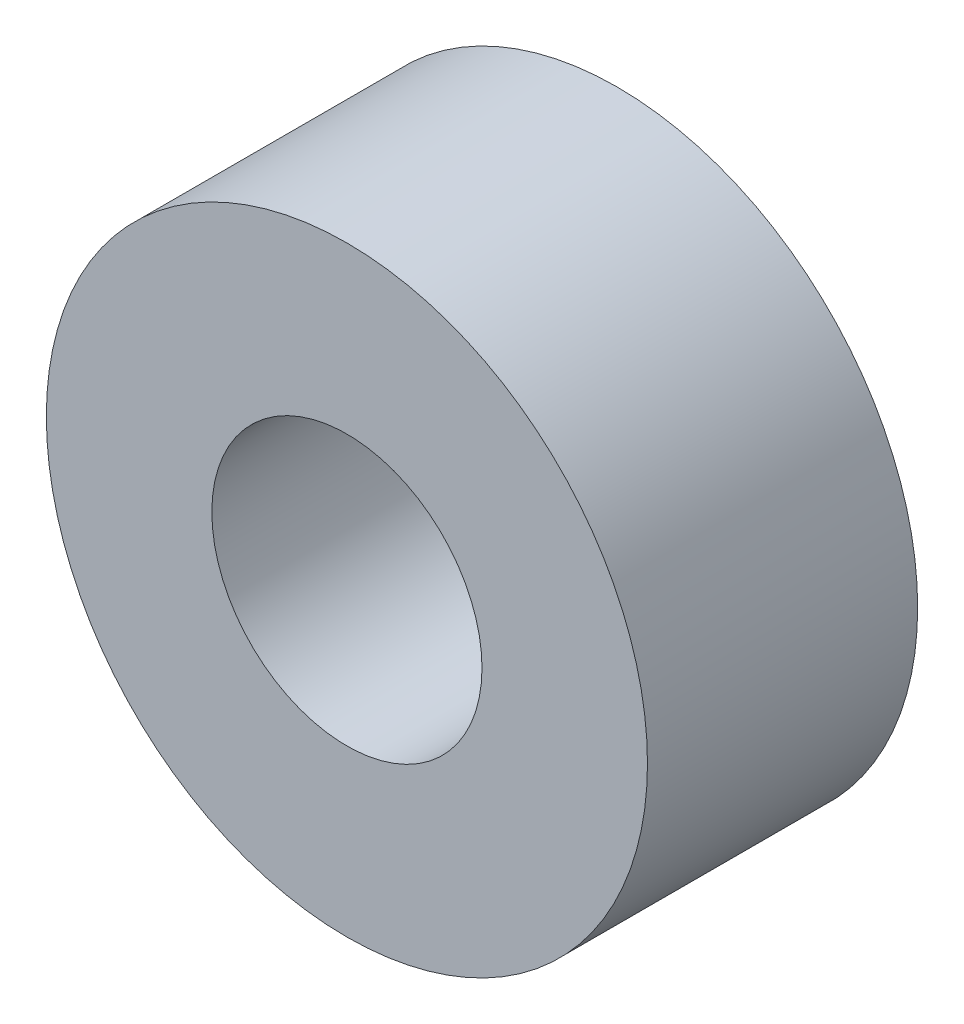
from build123d import *

# Parameters (mm, degrees)
SKETCH1_R           = 8.9
SKETCH1_R_2         = 4
BOSS_EXTRUDE1_DEPTH = 8


with BuildPart() as part:
    # Sketch1 → Boss-Extrude1 (new body)
    with BuildSketch(Plane.XY):
        Circle(SKETCH1_R)
        Circle(SKETCH1_R_2, mode=Mode.SUBTRACT)
    extrude(amount=BOSS_EXTRUDE1_DEPTH)


solid = part.part
